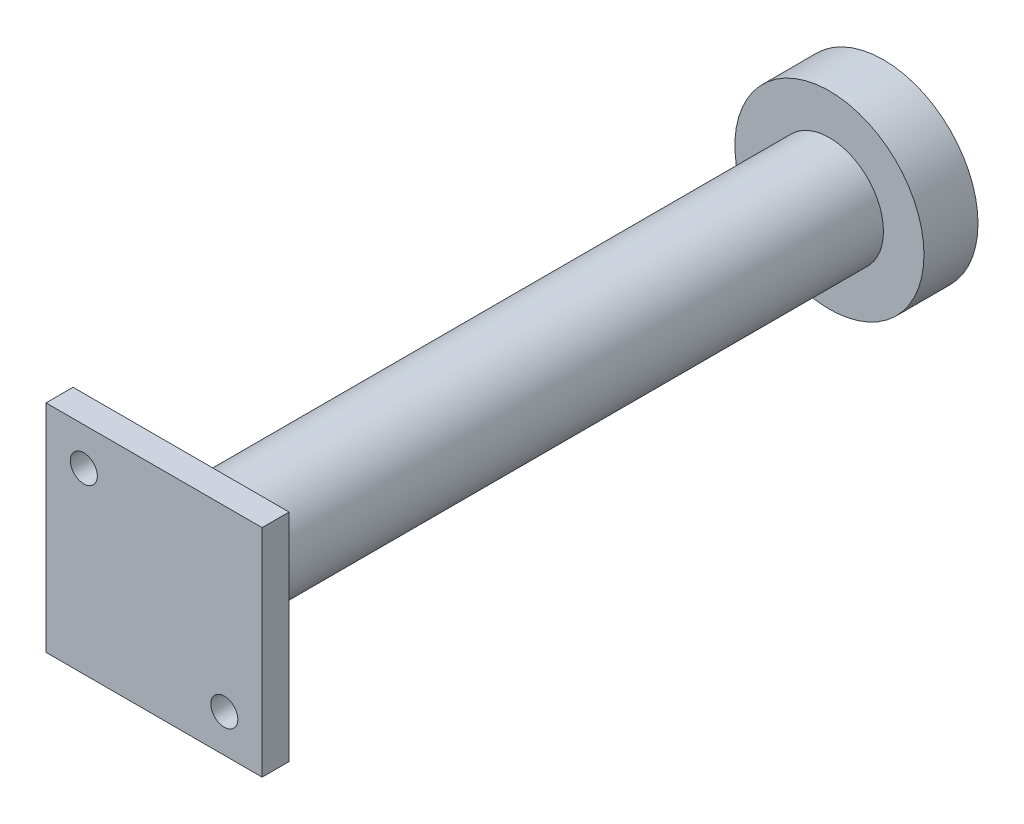
from build123d import *

# Parameters (mm, degrees)
ESQUISSE1_R             = 10
BOSS_EXTRU_1_DEPTH      = 100
ESQUISSE2_R             = 17.5
BOSS_EXTRU_2_DEPTH      = 30
ESQUISSE3_W             = 40
ESQUISSE3_H             = 40
BOSS_EXTRU_3_DEPTH      = 5
ESQUISSE4_R             = 2.5
ENL_V_MAT_EXTRU_1_DEPTH = 5
ESQUISSE5_OUTSIDE_W     = 71.274
ESQUISSE5_OUTSIDE_H     = 71.274
ESQUISSE5_OUTSIDE_R     = 10
ENL_V_MAT_EXTRU_3_DEPTH = 20


with BuildPart() as part:
    # Esquisse1 → Boss.-Extru.1 (new body)
    with BuildSketch(Plane.XY):
        Circle(ESQUISSE1_R)
    extrude(amount=BOSS_EXTRU_1_DEPTH)

    # Esquisse2 → Boss.-Extru.2 (add)
    with BuildSketch(Plane(origin=(0, 0, 0), x_dir=(-1, 0, 0), z_dir=(0, 0, -1))):
        Circle(ESQUISSE2_R)
    extrude(amount=BOSS_EXTRU_2_DEPTH)

    # Esquisse3 → Boss.-Extru.3 (add)
    with BuildSketch(Plane.XY.offset(100)):
        Rectangle(ESQUISSE3_W, ESQUISSE3_H)
    extrude(amount=BOSS_EXTRU_3_DEPTH)

    # Esquisse4 → Enlèv. mat.-Extru.1 (cut)
    with BuildSketch(Plane.XY.offset(105)):
        with Locations((-13, 13)):
            Circle(ESQUISSE4_R)
        with Locations((13, -13)):
            Circle(ESQUISSE4_R)
    extrude(amount=-ENL_V_MAT_EXTRU_1_DEPTH, mode=Mode.SUBTRACT)

    # Esquisse5 outside → Enlèv. mat.-Extru.3 (cut)
    with BuildSketch(Plane.XY):
        Rectangle(ESQUISSE5_OUTSIDE_W, ESQUISSE5_OUTSIDE_H)
        Circle(ESQUISSE5_OUTSIDE_R, mode=Mode.SUBTRACT)
    extrude(amount=-ENL_V_MAT_EXTRU_3_DEPTH, mode=Mode.SUBTRACT)


solid = part.part
